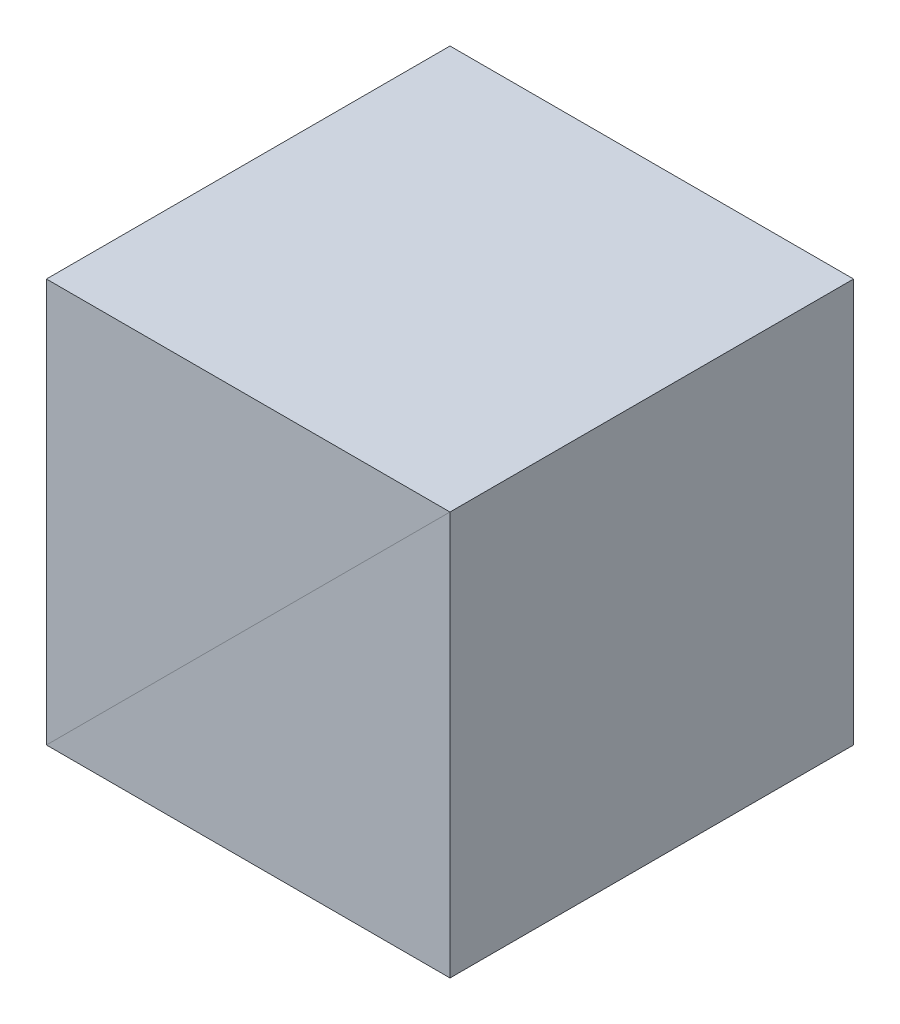
from build123d import *

# Parameters (mm, degrees)
EXTRUDE_1_DEPTH = 10


with BuildPart() as part:
    # 草图1 → 凸台-拉伸1 (new body, symmetric)
    with BuildSketch(Plane.XY):
        Polygon((-10, -10), (10, -10), (10, 10), align=None)
    extrude(amount=EXTRUDE_1_DEPTH, both=True)


with BuildPart() as body_2:
    # 镜向2: mirrored copy
    add(part.part.mirror(Plane(origin=(10, 10, 10), x_dir=(0, 0, 1), z_dir=(0.707106781, -0.707106781, 0))))


solid = Compound([part.part, body_2.part])
